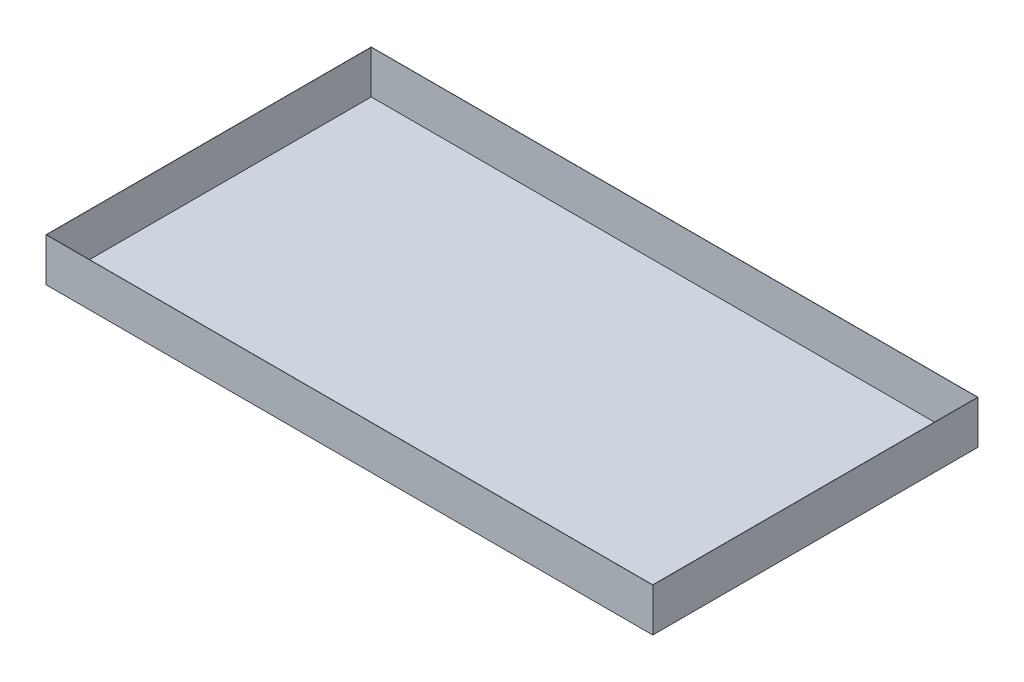
from build123d import *

# Parameters (mm, degrees)
SKETCH_1_W      = 28000
SKETCH_1_H      = 15000
EXTRUDE_1_DEPTH = 10
SKETCH_3_W      = 28020
SKETCH_3_H      = 15020
SKETCH_3_W_2    = 28000
SKETCH_3_H_2    = 15000
EXTRUDE_2_DEPTH = 2000


with BuildPart() as part:
    # 草图1 → 凸台-拉伸1 (new body)
    with BuildSketch(Plane(origin=(0, 0, 0), x_dir=(1, 0, 0), z_dir=(0, 1, 0))):
        Rectangle(SKETCH_1_W, SKETCH_1_H)
    extrude(amount=EXTRUDE_1_DEPTH)

    # 草图3 → 凸台-拉伸2 (add)
    with BuildSketch(Plane.XZ):
        Rectangle(SKETCH_3_W, SKETCH_3_H)
        Rectangle(SKETCH_3_W_2, SKETCH_3_H_2, mode=Mode.SUBTRACT)
    extrude(amount=-EXTRUDE_2_DEPTH)


solid = part.part
